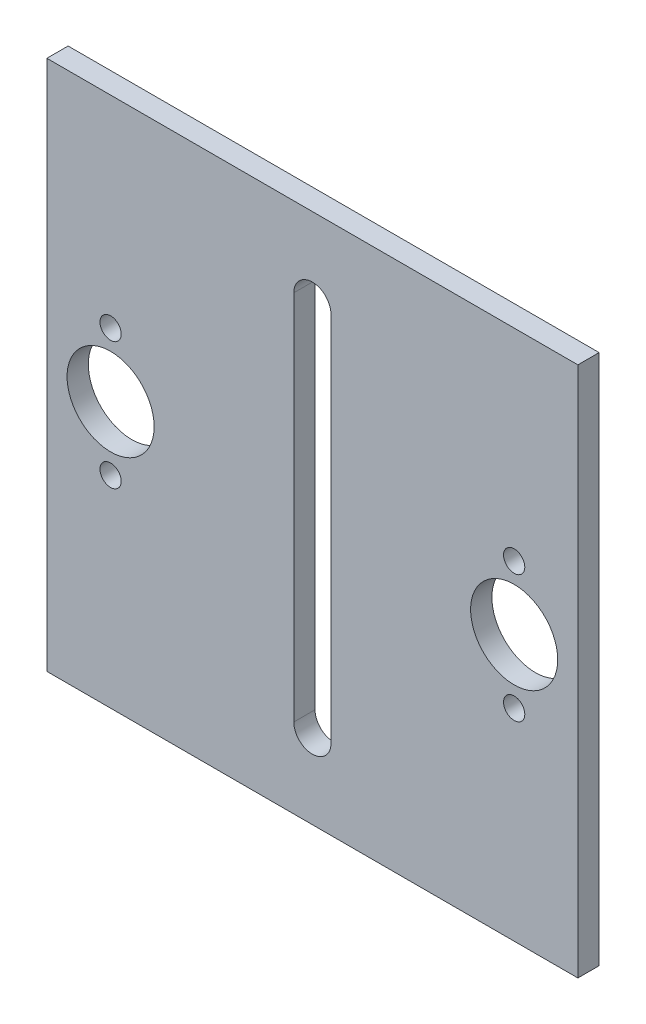
from build123d import *

# Parameters (mm, degrees)
SKETCH1_W                = 50
SKETCH1_H                = 50
PLATE_BODY_DEPTH         = 2
SKETCH2_R                = 4.1
SHAFT_BEARINGS_DEPTH     = 3
SKETCH3_R                = 1
BEARING_BOLT_HOLES_DEPTH = 3
CUT_EXTRUDE1_DEPTH       = 3


with BuildPart() as part:
    # Sketch1 → plate_body (new body)
    with BuildSketch(Plane.XY):
        with Locations((25, 25)):
            Rectangle(SKETCH1_W, SKETCH1_H)
    extrude(amount=PLATE_BODY_DEPTH)

    # Sketch2 → shaft_bearings (cut, through all)
    with BuildSketch(Plane.XY.offset(2)):
        with Locations((6, 25)):
            Circle(SKETCH2_R)
        with Locations((44, 25)):
            Circle(SKETCH2_R)
    extrude(amount=-SHAFT_BEARINGS_DEPTH, mode=Mode.SUBTRACT)

    # Sketch3 → bearing_bolt_holes (cut, through all)
    with BuildSketch(Plane.XY.offset(2)):
        with Locations((6, 31)):
            Circle(SKETCH3_R)
        with Locations((6, 19)):
            Circle(SKETCH3_R)
        with Locations((44, 31)):
            Circle(SKETCH3_R)
        with Locations((44, 19)):
            Circle(SKETCH3_R)
    extrude(amount=-BEARING_BOLT_HOLES_DEPTH, mode=Mode.SUBTRACT)

    # Sketch4 → Cut-Extrude1 (cut, through all)
    with BuildSketch(Plane.XY.offset(2)):
        with BuildLine():
            Line((26.75, 42.5), (26.75, 7.5))
            ThreePointArc((26.75, 7.5), (25, 5.75), (23.25, 7.5))
            Line((23.25, 7.5), (23.25, 42.5))
            ThreePointArc((23.25, 42.5), (25, 44.25), (26.75, 42.5))
        make_face()
    extrude(amount=-CUT_EXTRUDE1_DEPTH, mode=Mode.SUBTRACT)


solid = part.part
